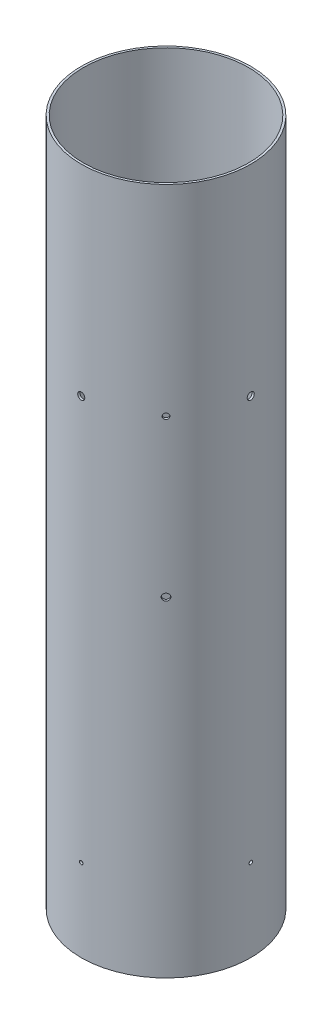
from build123d import *

# Parameters (mm, degrees)
SKETCH2_R                      = 78.359
SKETCH2_R_2                    = 76.3651
BOSS_EXTRUDE1_DEPTH            = 635
SKETCH4_R                      = 3.2639
CUT_EXTRUDE2_DEPTH             = 79.359
CIRPATTERN2_COUNT              = 4
CUT_EXTRUDE3_REACH             = 191.175
SKETCH5_R                      = 2.57937
CUT_EXTRUDE3_DIRECTION_2_DEPTH = 33.457360675
VENT_HOLE_REACH                = 191.175
SKETCH6_R                      = 3.175
F_4_CLEARANCE_HOLE1_D          = 3.2639
CIRPATTERN3_COUNT              = 2
CIRPATTERN3_ANGLE              = 90


with BuildPart() as part:
    # Sketch2 → Boss-Extrude1 (new body)
    with BuildSketch(Plane(origin=(0, 0, 0), x_dir=(1, 0, 0), z_dir=(0, 1, 0))):
        Circle(SKETCH2_R)
        Circle(SKETCH2_R_2, mode=Mode.SUBTRACT)
    extrude(amount=BOSS_EXTRUDE1_DEPTH)

    # Sketch4 → Cut-Extrude2 (cut, symmetric)
    with BuildSketch(Plane.XY):
        with Locations((0, 449.5038)):
            Circle(SKETCH4_R)
    cut_extrude2 = extrude(amount=CUT_EXTRUDE2_DEPTH, both=True, mode=Mode.SUBTRACT)

    # CirPattern2: Cut-Extrude2 ×4 about axis
    cirpattern2_axis = Axis((0, 635, 0), (0, 1, 0))
    for i in range(1, CIRPATTERN2_COUNT):
        add(cut_extrude2.rotate(cirpattern2_axis, i * 360 / CIRPATTERN2_COUNT), mode=Mode.SUBTRACT)

    # Sketch5 → Cut-Extrude3 (cut, up to next)
    with BuildSketch(Plane(origin=(55.408180267, 0, 55.408180267), x_dir=(0, -1, 0), z_dir=(0.707106781, 0, 0.707106781)), mode=Mode.PRIVATE) as cut_extrude3_sk1:
        with Locations((-449.5038, 0)):
            Circle(SKETCH5_R)
    cut_extrude3_tool1 = extrude(cut_extrude3_sk1.sketch, amount=-CUT_EXTRUDE3_REACH, mode=Mode.PRIVATE) & part.part
    add(cut_extrude3_tool1.solids().sort_by_distance((55.40818, 449.5038, 55.40818))[0], mode=Mode.SUBTRACT)

    # Sketch5 → Cut-Extrude3 direction 2 (cut)
    with BuildSketch(Plane(origin=(55.408180267, 0, 55.408180267), x_dir=(0, -1, 0), z_dir=(0.707106781, 0, 0.707106781))):
        with Locations((-449.5038, 0)):
            Circle(SKETCH5_R)
    extrude(amount=CUT_EXTRUDE3_DIRECTION_2_DEPTH, mode=Mode.SUBTRACT)

    # Sketch6 → Vent Hole (cut, up to next)
    with BuildSketch(Plane(origin=(189.175360534, 0, -78.359), x_dir=(-0.707106781, 0, 0.707106781), z_dir=(-0.707106781, 0, -0.707106781)), mode=Mode.PRIVATE) as vent_hole_sk1:
        with Locations((189.175360534, 304.8)):
            Circle(SKETCH6_R)
    vent_hole_tool1 = extrude(vent_hole_sk1.sketch, amount=VENT_HOLE_REACH, mode=Mode.PRIVATE) & part.part
    add(vent_hole_tool1.solids().sort_by_distance((55.40818, 304.8, 55.40818))[0], mode=Mode.SUBTRACT)

    # #4 Clearance Hole1 (through all)
    with Locations(Plane.XY.offset(78.359)):
        with Locations((0, 76.2)):
            f_4_clearance_hole1 = Hole(F_4_CLEARANCE_HOLE1_D / 2)

    # CirPattern3: #4 Clearance Hole1 ×2 about axis
    cirpattern3_axis = Axis((0, 0, 0), (0, 1, 0))
    for i in range(1, CIRPATTERN3_COUNT):
        add(f_4_clearance_hole1.rotate(cirpattern3_axis, i * CIRPATTERN3_ANGLE / (CIRPATTERN3_COUNT - 1)), mode=Mode.SUBTRACT)


solid = part.part
